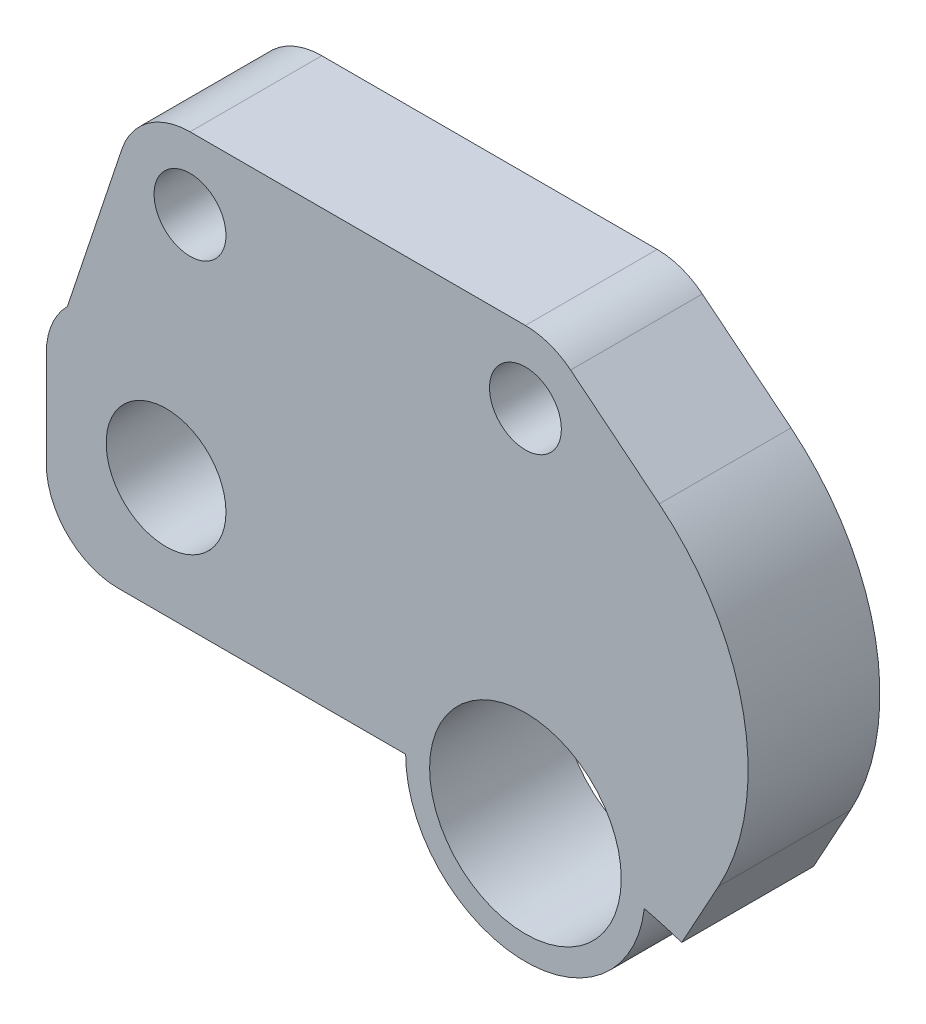
from build123d import *

# Parameters (mm, degrees)
CROQUIS1_R              = 4
CROQUIS1_R_2            = 2.5
CROQUIS1_R_3            = 1.5
SALIENTE_EXTRUIR1_DEPTH = 5.5
CORTAR_EXTRUIR1_DEPTH   = 10
REDONDEO1_R             = 10


with BuildPart() as part:
    # Croquis1 → Saliente-Extruir1 (new body)
    with BuildSketch(Plane.XY):
        with BuildLine():
            ThreePointArc((13.175908043, 16.287969402), (20.207859701, 17.03070481), (19.465124293, 24.062656467))
            Line((19.465124293, 24.062656467), (1.886764875, 38.28240612))
            ThreePointArc((1.886764875, 38.28240612), (1.000695169, 38.778181249), (0, 38.95))
            Line((0, 38.95), (-14, 38.95))
            ThreePointArc((-14, 38.95), (-15.75421382, 38.383666755), (-16.84611457, 36.898489248))
            Line((-16.84611457, 36.898489248), (-19.121320344, 30.071320344))
            ThreePointArc((-19.121320344, 30.071320344), (-19.771638598, 29.098050297), (-20, 27.95))
            Line((-20, 27.95), (-20, 23.95))
            ThreePointArc((-20, 23.95), (-19.121320344, 21.828679656), (-17, 20.95))
            Line((-17, 20.95), (-5, 20.95))
            ThreePointArc((-5, 20.95), (-0.298863721, 15.958939945), (4.964272191, 20.353341289))
            ThreePointArc((4.964272191, 20.353341289), (9.295071106, 18.775093958), (13.175908043, 16.287969402))
        make_face()
        with Locations((0, 20.95)):
            Circle(CROQUIS1_R, mode=Mode.SUBTRACT)
        with Locations((-15, 25.95)):
            Circle(CROQUIS1_R_2, mode=Mode.SUBTRACT)
        with Locations((0, 35.95)):
            Circle(CROQUIS1_R_3, mode=Mode.SUBTRACT)
        with Locations((-14, 35.95)):
            Circle(CROQUIS1_R_3, mode=Mode.SUBTRACT)
    extrude(amount=SALIENTE_EXTRUIR1_DEPTH)

    # Croquis2 → Cortar-Extruir1 (cut)
    with BuildSketch(Plane.XY.offset(5.5)):
        with BuildLine():
            Line((12.087138576, 30.030967124), (6.52630373, 19.907532736))
            ThreePointArc((6.52630373, 19.907532736), (10.015967096, 18.400622357), (13.175908043, 16.287969402))
            ThreePointArc((13.175908043, 16.287969402), (20.207859701, 17.03070481), (19.465124293, 24.062656467))
            Line((19.465124293, 24.062656467), (12.087138576, 30.030967124))
        make_face()
    extrude(amount=-CORTAR_EXTRUIR1_DEPTH, mode=Mode.SUBTRACT)

    # Redondeo1
    redondeo1_edges = [part.edges().sort_by_distance(p)[0] for p in [
        (12.087138576, 30.030967124, 2.75),
    ]]
    fillet(redondeo1_edges, radius=REDONDEO1_R)


solid = part.part
